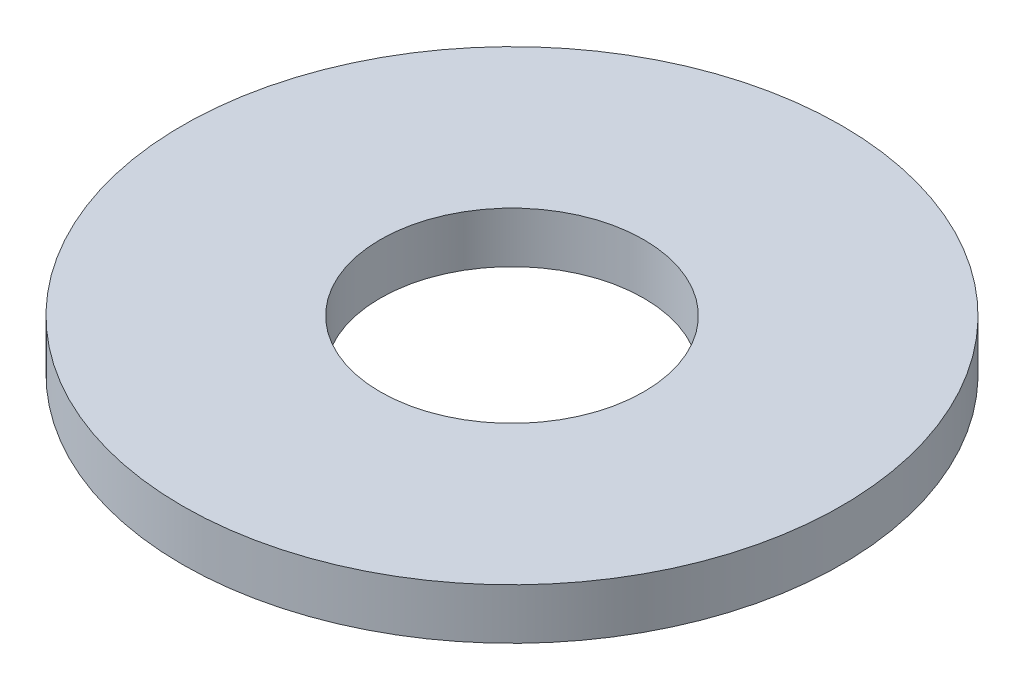
from build123d import *

# Parameters (mm, degrees)
SKETCH1_R           = 6.5
SKETCH1_R_2         = 2.6
BOSS_EXTRUDE1_DEPTH = 1
SCALE1_SCALE        = 0.6


with BuildPart() as part:
    # Sketch1 → Boss-Extrude1 (new body)
    with BuildSketch(Plane(origin=(0, 0, 0), x_dir=(1, 0, 0), z_dir=(0, 1, 0))):
        Circle(SKETCH1_R)
        Polygon((-2.742413779, -4.75), (2.742413779, -4.75), (5.484827557, 0), (2.742413779, 4.75), (-2.742413779, 4.75), (-5.484827557, 0), align=None, mode=Mode.SUBTRACT)
        Polygon((-5.484827557, 0), (-2.742413779, -4.75), (2.742413779, -4.75), (5.484827557, 0), (2.742413779, 4.75), (-2.742413779, 4.75), align=None)
        Circle(SKETCH1_R_2, mode=Mode.SUBTRACT)
    extrude(amount=-BOSS_EXTRUDE1_DEPTH)


with BuildPart() as part_1:
    # Scale1: scaled about (0, -0.5, 0)
    add(part.part.scale(SCALE1_SCALE).moved(Location((0, -0.2, 0))))


solid = part_1.part
